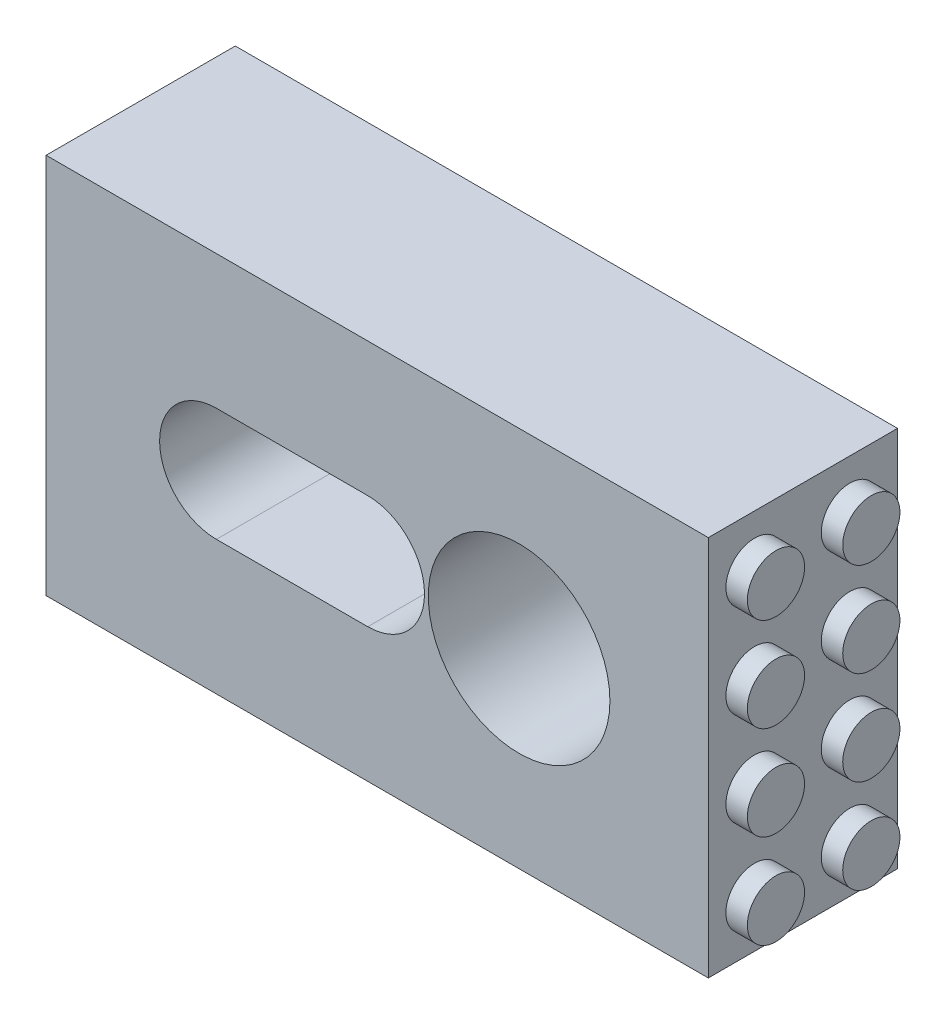
from build123d import *

# Parameters (mm, degrees)
SKETCH1_W               = 55.5625
SKETCH1_H               = 31.75
BOSS_EXTRUDE1_DEPTH     = 28.575
SKETCH2_R               = 7.62
CUT_EXTRUDE1_DEPTH      = 13.335
CUT_EXTRUDE2_DEPTH      = 12.7
SKETCH4_R               = 1.8415
CUT_EXTRUDE3_DEPTH      = 25.4
CUT_EXTRUDE4_DEPTH      = 17.78
SKETCH6_W               = 55.5625
SKETCH6_H               = 28.575
CUT_EXTRUDE5_DEPTH      = 15.875
SKETCH7_R               = 2.778125
CUT_EXTRUDE7_DEPTH      = 7.9375
SKETCH8_R               = 2.4
BOSS_EXTRUDE2_DEPTH     = 1.8
BOSS_EXTRUDE3_DEPTH     = 4
SKETCH11_W              = 55.5625
SKETCH11_H              = 0.575
CUT_EXTRUDE8_DEPTH      = 102.162047202
CUT_EXTRUDE8_DEPTH_BACK = 102.162047202
SKETCH12_R              = 3.255
SKETCH12_R_2            = 2.45
CUT_EXTRUDE10_DEPTH     = 2.1


with BuildPart() as part:
    # Sketch1 → Boss-Extrude1 (new body)
    with BuildSketch(Plane(origin=(0, 0, 0), x_dir=(1, 0, 0), z_dir=(0, 1, 0))):
        with Locations((-66.667749699, 35.16562105)):
            Rectangle(SKETCH1_W, SKETCH1_H)
    extrude(amount=BOSS_EXTRUDE1_DEPTH)

    # Sketch2 → Cut-Extrude1 (cut)
    with BuildSketch(Plane.XY.offset(-19.29062105)):
        with Locations((-54.761499699, 16)):
            Circle(SKETCH2_R)
    extrude(amount=-CUT_EXTRUDE1_DEPTH, mode=Mode.SUBTRACT)

    # Sketch3 → Cut-Extrude2 (cut)
    with BuildSketch(Plane.XY.offset(-19.29062105)):
        with BuildLine():
            Line((-80.161499699, 20.7625), (-67.461499699, 20.7625))
            ThreePointArc((-67.461499699, 20.7625), (-62.698999699, 16), (-67.461499699, 11.2375))
            Line((-67.461499699, 11.2375), (-80.161499699, 11.2375))
            ThreePointArc((-80.161499699, 11.2375), (-84.923999699, 16), (-80.161499699, 20.7625))
        make_face()
    extrude(amount=-CUT_EXTRUDE2_DEPTH, mode=Mode.SUBTRACT)

    # Sketch4 → Cut-Extrude3 (cut)
    with BuildSketch(Plane.XY.offset(-31.99062105)):
        with Locations((-80.161499699, 16)):
            Circle(SKETCH4_R)
        with Locations((-67.461499699, 16)):
            Circle(SKETCH4_R)
    extrude(amount=-CUT_EXTRUDE3_DEPTH, mode=Mode.SUBTRACT)

    # Sketch5 → Cut-Extrude4 (cut)
    with BuildSketch(Plane(origin=(0, 0, -51.04062105), x_dir=(-1, 0, 0), z_dir=(0, 0, -1))):
        with BuildLine():
            Line((67.461499699, 11.2375), (80.161499699, 11.2375))
            ThreePointArc((80.161499699, 11.2375), (84.923999699, 16), (80.161499699, 20.7625))
            Line((80.161499699, 20.7625), (67.461499699, 20.7625))
            ThreePointArc((67.461499699, 20.7625), (62.698999699, 16), (67.461499699, 11.2375))
        make_face()
    extrude(amount=-CUT_EXTRUDE4_DEPTH, mode=Mode.SUBTRACT)

    # Sketch6 → Cut-Extrude5 (cut)
    with BuildSketch(Plane(origin=(0, 0, -51.04062105), x_dir=(-1, 0, 0), z_dir=(0, 0, -1))):
        with Locations((66.667749699, 14.2875)):
            Rectangle(SKETCH6_W, SKETCH6_H)
    extrude(amount=-CUT_EXTRUDE5_DEPTH, mode=Mode.SUBTRACT)

    # Sketch7 → Cut-Extrude7 (cut)
    with BuildSketch(Plane.XY.offset(-32.62562105)):
        with Locations((-54.761499699, 16)):
            Circle(SKETCH7_R)
    extrude(amount=-CUT_EXTRUDE7_DEPTH, mode=Mode.SUBTRACT)

    # Sketch8 → Boss-Extrude2 (add)
    with BuildSketch(Plane(origin=(-38.886499699, 0, 0), x_dir=(0, 0, -1), z_dir=(1, 0, 0))):
        with Locations(Location((31.16562105, 4, 0), (0, 0, 180))):
            Circle(SKETCH8_R)
        with Locations(Location((23.16562105, 4, 0), (0, 0, 180))):
            Circle(SKETCH8_R)
        with Locations(Location((23.16562105, 11.874, 0), (0, 0, 180))):
            Circle(SKETCH8_R)
        with Locations(Location((31.16562105, 11.874, 0), (0, 0, 180))):
            Circle(SKETCH8_R)
        with Locations(Location((23.16562105, 19.748, 0), (0, 0, 180))):
            Circle(SKETCH8_R)
        with Locations(Location((31.16562105, 19.748, 0), (0, 0, 180))):
            Circle(SKETCH8_R)
        with Locations(Location((23.16562105, 27.622, 0), (0, 0, 156.604030276))):
            Circle(SKETCH8_R)
        with Locations(Location((31.16562105, 27.622, 0), (0, 0, 156.604030276))):
            Circle(SKETCH8_R)
    extrude(amount=BOSS_EXTRUDE2_DEPTH)

    # Sketch10 → Boss-Extrude3 (add)
    with BuildSketch(Plane(origin=(0, 28.575, 0), x_dir=(1, 0, 0), z_dir=(0, 1, 0))):
        Polygon((-38.886499699, 19.29062105), (-38.886499699, 20.962942907), (-38.886499699, 25.368299192), (-38.886499699, 28.962942907), (-38.886499699, 33.368299192), (-38.886499699, 35.16562105), (-94.448999699, 35.16562105), (-94.448999699, 19.29062105), align=None)
    extrude(amount=BOSS_EXTRUDE3_DEPTH)

    # Sketch11 → Cut-Extrude8 (cut, two sides)
    with BuildSketch(Plane.XY.offset(-19.29062105)) as cut_extrude8_sk:
        with Locations((-66.667749699, 32.2875)):
            Rectangle(SKETCH11_W, SKETCH11_H)
    extrude(amount=CUT_EXTRUDE8_DEPTH, mode=Mode.SUBTRACT)
    extrude(cut_extrude8_sk.sketch, amount=-CUT_EXTRUDE8_DEPTH_BACK, mode=Mode.SUBTRACT)

    # Sketch12 → Cut-Extrude10 (cut)
    with BuildSketch(Plane.ZY.offset(94.448999699)):
        Polygon((-33.96562105, 30.8), (-31.46562105, 30.8), (-31.46562105, 30.5), (-30.86562105, 30.5), (-30.86562105, 30.8), (-23.59062105, 30.8), (-23.59062105, 30.5), (-22.99062105, 30.5), (-22.99062105, 30.8), (-20.49062105, 30.8), (-20.49062105, 28.3), (-20.79062105, 28.3), (-20.79062105, 27.7), (-20.49062105, 27.7), (-20.49062105, 20.426), (-20.79062105, 20.426), (-20.79062105, 19.826), (-20.49062105, 19.826), (-20.49062105, 12.552), (-20.79062105, 12.552), (-20.79062105, 11.952), (-20.49062105, 11.952), (-20.49062105, 4.678), (-20.79062105, 4.678), (-20.79062105, 4.078), (-20.49062105, 4.078), (-20.49062105, 1.2), (-22.99062105, 1.2), (-22.99062105, 1.5), (-23.59062105, 1.5), (-23.59062105, 1.2), (-30.86562105, 1.2), (-30.86562105, 1.5), (-31.46562105, 1.5), (-31.46562105, 1.2), (-33.96562105, 1.2), (-33.96562105, 4.078), (-33.66562105, 4.078), (-33.66562105, 4.678), (-33.96562105, 4.678), (-33.96562105, 11.952), (-33.66562105, 11.952), (-33.66562105, 12.552), (-33.96562105, 12.552), (-33.96562105, 19.826), (-33.66562105, 19.826), (-33.66562105, 20.426), (-33.96562105, 20.426), (-33.96562105, 27.7), (-33.66562105, 27.7), (-33.66562105, 28.3), (-33.96562105, 28.3), align=None)
        with Locations((-27.29062105, 24)):
            Circle(SKETCH12_R, mode=Mode.SUBTRACT)
        with Locations((-27.29062105, 16)):
            Circle(SKETCH12_R, mode=Mode.SUBTRACT)
        with Locations((-27.29062105, 8)):
            Circle(SKETCH12_R, mode=Mode.SUBTRACT)
        with Locations((-27.29062105, 8)):
            Circle(SKETCH12_R_2)
        with Locations((-27.29062105, 16)):
            Circle(SKETCH12_R_2)
        with Locations((-27.29062105, 24)):
            Circle(SKETCH12_R_2)
    extrude(amount=-CUT_EXTRUDE10_DEPTH, mode=Mode.SUBTRACT)


solid = part.part
